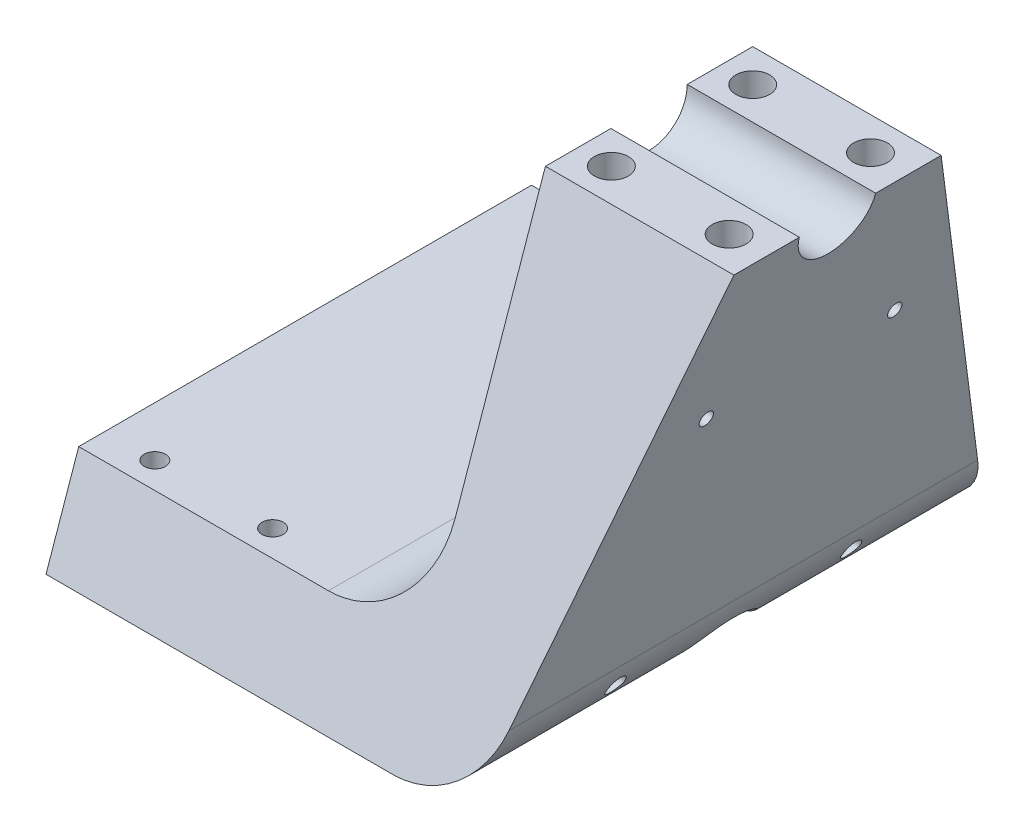
from build123d import *

# Parameters (mm, degrees)
BOSS_EXTRUDE1_DEPTH     = 110
SKETCH2_R               = 8.1
CUT_EXTRUDE1_DEPTH      = 41
CUT_EXTRUDE2_DEPTH      = 74
CUT_EXTRUDE2_DEPTH_BACK = 41
SKETCH3_R               = 2.25
CUT_EXTRUDE3_DEPTH      = 21
SKETCH5_R               = 3.6
CUT_EXTRUDE4_DEPTH      = 17
SKETCH6_R               = 10
SKETCH6_R_2             = 2
CUT_EXTRUDE5_DEPTH      = 149
SKETCH7_R               = 1.5
CUT_EXTRUDE6_DEPTH      = 43


with BuildPart() as part:
    # Sketch1 → Boss-Extrude1 (new body)
    with BuildSketch(Plane.XY):
        with BuildLine():
            Line((0, 0), (40, 0))
            Line((40, 0), (20, -79.858784278))
            ThreePointArc((20, -79.858784278), (12.904134464, -90.766668728), (0.599169725, -95))
            Line((0.599169725, -95), (-73, -95))
            Line((-73, -95), (-73, -75))
            Line((-73, -75), (-20, -75))
            ThreePointArc((-20, -75), (-5.857864376, -69.142135624), (0, -55))
            Line((0, -55), (0, 0))
        make_face()
    extrude(amount=BOSS_EXTRUDE1_DEPTH)

    # Sketch2 → Cut-Extrude1 (cut, through all)
    with BuildSketch(Plane(origin=(0, -4.784896585, 0), x_dir=(0, 0, -1), z_dir=(1, 0, 0))):
        with Locations((-55, 4.784896585)):
            Circle(SKETCH2_R)
    extrude(amount=CUT_EXTRUDE1_DEPTH, mode=Mode.SUBTRACT)

    # Sketch4 → Cut-Extrude2 (cut, two sides)
    with BuildSketch(Plane.ZY) as cut_extrude2_sk:
        Polygon((33, 0), (0, -95), (0, 0), align=None)
        Polygon((77, 0), (110, -95), (110, 0), align=None)
    extrude(amount=CUT_EXTRUDE2_DEPTH, mode=Mode.SUBTRACT)
    extrude(cut_extrude2_sk.sketch, amount=-CUT_EXTRUDE2_DEPTH_BACK, mode=Mode.SUBTRACT)

    # Sketch3 → Cut-Extrude3 (cut, through all)
    with BuildSketch(Plane(origin=(0, -75, 0), x_dir=(1, 0, 0), z_dir=(0, 1, 0))):
        with Locations((-62.4, -12.5)):
            Circle(SKETCH3_R)
        with Locations((-62.4, -97.5)):
            Circle(SKETCH3_R)
        with Locations((-37.4, -12.5)):
            Circle(SKETCH3_R)
        with Locations((-37.4, -97.5)):
            Circle(SKETCH3_R)
    extrude(amount=-CUT_EXTRUDE3_DEPTH, mode=Mode.SUBTRACT)

    # Sketch5 → Cut-Extrude4 (cut)
    with BuildSketch(Plane(origin=(0, 0, 0), x_dir=(1, 0, 0), z_dir=(0, 1, 0))):
        with Locations((7, -40)):
            Circle(SKETCH5_R)
        with Locations((32, -40)):
            Circle(SKETCH5_R)
        with Locations((7, -70)):
            Circle(SKETCH5_R)
        with Locations((32, -70)):
            Circle(SKETCH5_R)
    extrude(amount=-CUT_EXTRUDE4_DEPTH, mode=Mode.SUBTRACT)

    # Sketch6 → Cut-Extrude5 (cut)
    with BuildSketch(Plane.ZY.offset(73)):
        with Locations((55, -95)):
            Circle(SKETCH6_R)
        with Locations((30, -85)):
            Circle(SKETCH6_R_2)
        with Locations((80, -85)):
            Circle(SKETCH6_R_2)
    extrude(amount=-CUT_EXTRUDE5_DEPTH, mode=Mode.SUBTRACT)

    # Sketch7 → Cut-Extrude6 (cut)
    with BuildSketch(Plane(origin=(37.639221534, -9.426444911, 0), x_dir=(0, 0, -1), z_dir=(0.970041514, -0.242939214, 0))):
        with Locations((-75, -22.607551707)):
            Circle(SKETCH7_R)
        with Locations((-35, -22.607551707)):
            Circle(SKETCH7_R)
    extrude(amount=-CUT_EXTRUDE6_DEPTH, mode=Mode.SUBTRACT)


solid = part.part
